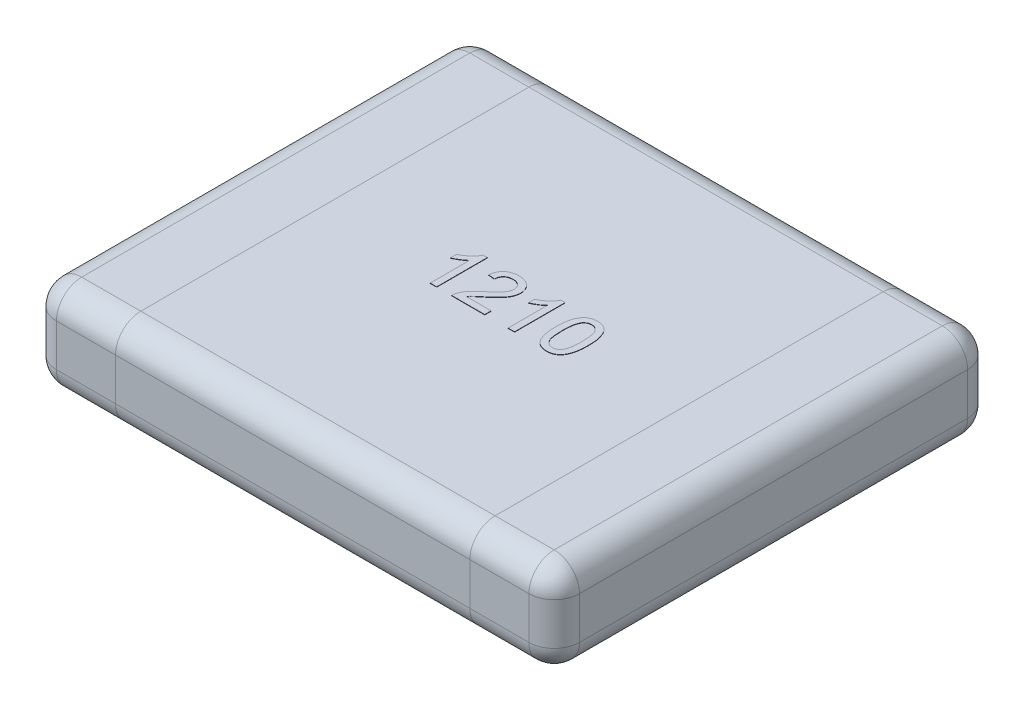
from build123d import *

# Parameters (mm, degrees)
SKETCH1_W      = 3.1
SKETCH1_H      = 2.6
EXTRUDE1_DEPTH = 0.55
FILLET1_R      = 0.15
EXTRUDE2_DEPTH = 0.002


with BuildPart() as part:
    # Sketch1 → Extrude1 (new body)
    with BuildSketch(Plane(origin=(0, 0, 0), x_dir=(1, 0, 0), z_dir=(0, 1, 0))):
        Rectangle(SKETCH1_W, SKETCH1_H)
    extrude(amount=EXTRUDE1_DEPTH)

    # Fillet1
    fillet1_edges = [part.edges().sort_by_distance(p)[0] for p in [
        (1.55, 0.55, 0),
        (0, 0.55, -1.3),
        (-1.55, 0.55, 0),
        (0, 0, -1.3),
        (1.55, 0, 0),
        (0, 0, 1.3),
        (-1.55, 0, 0),
        (0, 0.55, 1.3),
        (-1.55, 0.275, -1.3),
        (1.55, 0.275, -1.3),
        (1.55, 0.275, 1.3),
        (-1.55, 0.275, 1.3),
    ]]
    fillet(fillet1_edges, radius=FILLET1_R)

    # Sketch3 → Extrude2 (add)
    with BuildSketch(Plane(origin=(0, 0.55, 0), x_dir=(1, 0, 0), z_dir=(0, 1, 0))):
        with BuildLine():
            Line((-0.296153846, -0.15), (-0.334615385, -0.15))
            Line((-0.334615385, -0.15), (-0.334615385, 0.083774038))
            add(Edge.make_bspline(
                [(-0.334615385, 0.083774038), (-0.336830003, 0.081638311), (-0.341432846, 0.077199436), (-0.349213465, 0.070917319), (-0.35789763, 0.064550127), (-0.367372572, 0.05842736), (-0.377030672, 0.052663436), (-0.386363982, 0.047479672), (-0.39521668, 0.04309295), (-0.401047999, 0.040694273), (-0.403846154, 0.039543269)],
                knots=[0, 0, 0, 0, 9.226e-06, 1.9175e-05, 2.9969e-05, 4.1521e-05, 5.3002e-05, 6.3707e-05, 7.3544e-05, 8.2619e-05, 8.2619e-05, 8.2619e-05, 8.2619e-05], degree=3))
            Line((-0.403846154, 0.039543269), (-0.403846154, 0.075))
            add(Edge.make_bspline(
                [(-0.403846154, 0.075), (-0.399040034, 0.077475162), (-0.389567455, 0.082353558), (-0.37618475, 0.09077922), (-0.363690555, 0.099912985), (-0.352291699, 0.10975283), (-0.342073351, 0.119810917), (-0.333462201, 0.129959923), (-0.326256938, 0.139827828), (-0.322641922, 0.146709597), (-0.320913462, 0.15)],
                knots=[0, 0, 0, 0, 1.6212e-05, 3.1953e-05, 4.7386e-05, 6.26e-05, 7.7091e-05, 9.0349e-05, 0.000102505, 0.000113642, 0.000113642, 0.000113642, 0.000113642], degree=3))
            Line((-0.320913462, 0.15), (-0.296153846, 0.15))
            Line((-0.296153846, 0.15), (-0.296153846, -0.15))
        make_face()
        with BuildLine():
            Line((-0.011538462, -0.111538462), (-0.011538462, -0.15))
            Line((-0.011538462, -0.15), (-0.207692308, -0.15))
            add(Edge.make_bspline(
                [(-0.207692308, -0.15), (-0.207696323, -0.147714123), (-0.207704342, -0.14315003), (-0.206932024, -0.136400026), (-0.205722419, -0.129739566), (-0.204354719, -0.125468478), (-0.203665865, -0.123317308)],
                knots=[0, 0, 0, 0, 6.852e-06, 1.3681e-05, 2.0352e-05, 2.7121e-05, 2.7121e-05, 2.7121e-05, 2.7121e-05], degree=3))
            add(Edge.make_bspline(
                [(-0.203665865, -0.123317308), (-0.202393093, -0.119802551), (-0.199801518, -0.112645929), (-0.19455096, -0.102319922), (-0.188375063, -0.092056365), (-0.182361958, -0.08370038), (-0.176855252, -0.077024532), (-0.172237162, -0.071801454), (-0.167119471, -0.066455018), (-0.161506278, -0.060986201), (-0.155451607, -0.055359583), (-0.148947197, -0.049556401), (-0.141916239, -0.043684801), (-0.137007895, -0.039792861), (-0.134495192, -0.037800481)],
                knots=[0, 0, 0, 0, 1.1205e-05, 2.2816e-05, 3.4678e-05, 4.712e-05, 5.3653e-05, 6.0635e-05, 6.8031e-05, 7.5851e-05, 8.4142e-05, 9.2826e-05, 0.000101998, 0.000111618, 0.000111618, 0.000111618, 0.000111618], degree=3))
            add(Edge.make_bspline(
                [(-0.134495192, -0.037800481), (-0.130635061, -0.034551471), (-0.123202132, -0.028295295), (-0.112705672, -0.019011711), (-0.103118865, -0.010391377), (-0.094594368, -0.002283205), (-0.087062462, 0.005234162), (-0.080505461, 0.012143692), (-0.074866946, 0.018423822), (-0.070215752, 0.024301865), (-0.066291398, 0.029852373), (-0.062965854, 0.035266551), (-0.060194454, 0.040638972), (-0.057886249, 0.045952637), (-0.056060655, 0.05123027), (-0.054816253, 0.056487246), (-0.053972343, 0.061671403), (-0.053887909, 0.065120999), (-0.053846154, 0.066826923)],
                knots=[0, 0, 0, 0, 1.5136e-05, 2.9145e-05, 4.2036e-05, 5.3811e-05, 6.4435e-05, 7.3957e-05, 8.2386e-05, 8.9745e-05, 9.643e-05, 0.000102769, 0.00010879, 0.00011455, 0.000120137, 0.000125516, 0.000130743, 0.000135857, 0.000135857, 0.000135857, 0.000135857], degree=3))
            add(Edge.make_bspline(
                [(-0.053846154, 0.066826923), (-0.053887914, 0.068512943), (-0.053969845, 0.071820821), (-0.054747201, 0.076661881), (-0.055829343, 0.081323937), (-0.057578837, 0.085723063), (-0.059661262, 0.089989532), (-0.062332474, 0.093988532), (-0.065422517, 0.097819726), (-0.068960356, 0.101382104), (-0.072824504, 0.104724183), (-0.077142138, 0.107502263), (-0.081629679, 0.110003363), (-0.086441941, 0.11201439), (-0.091571106, 0.113491124), (-0.096979835, 0.114562852), (-0.10266727, 0.115242385), (-0.106548545, 0.115336486), (-0.108533654, 0.115384615)],
                knots=[0, 0, 0, 0, 5.054e-06, 9.915e-06, 1.4681e-05, 1.938e-05, 2.4083e-05, 2.89e-05, 3.3772e-05, 3.8829e-05, 4.3946e-05, 4.9063e-05, 5.4199e-05, 5.9345e-05, 6.4669e-05, 7.0185e-05, 7.5872e-05, 8.1827e-05, 8.1827e-05, 8.1827e-05, 8.1827e-05], degree=3))
            add(Edge.make_bspline(
                [(-0.108533654, 0.115384615), (-0.110618956, 0.115336725), (-0.114700045, 0.115242999), (-0.120665504, 0.114560756), (-0.126328674, 0.113518381), (-0.131676037, 0.111924678), (-0.136701084, 0.109917004), (-0.141383351, 0.107389877), (-0.145797819, 0.104537208), (-0.149805459, 0.101159863), (-0.153429516, 0.097415076), (-0.156646835, 0.093338135), (-0.159282944, 0.088850365), (-0.161459952, 0.084050442), (-0.163210448, 0.078923275), (-0.164481249, 0.07342967), (-0.165174098, 0.067585487), (-0.165313425, 0.063583392), (-0.165384615, 0.061538462)],
                knots=[0, 0, 0, 0, 6.255e-06, 1.2241e-05, 1.7992e-05, 2.3507e-05, 2.8953e-05, 3.4195e-05, 3.9446e-05, 4.4693e-05, 4.9878e-05, 5.506e-05, 6.0233e-05, 6.5451e-05, 7.0848e-05, 7.6461e-05, 8.2334e-05, 8.8471e-05, 8.8471e-05, 8.8471e-05, 8.8471e-05], degree=3))
            Line((-0.165384615, 0.061538462), (-0.203846154, 0.065384615))
            add(Edge.make_bspline(
                [(-0.203846154, 0.065384615), (-0.203452638, 0.068736632), (-0.202687086, 0.075257693), (-0.200780201, 0.084702351), (-0.198103106, 0.09348859), (-0.194899737, 0.101738909), (-0.190884012, 0.109312863), (-0.18634458, 0.11636711), (-0.18099053, 0.122677919), (-0.175075725, 0.128444216), (-0.168535362, 0.133525841), (-0.161430878, 0.137965346), (-0.153765522, 0.141678718), (-0.145581988, 0.144753235), (-0.136861488, 0.147085948), (-0.12761636, 0.148758724), (-0.117831734, 0.149789842), (-0.111120341, 0.149928948), (-0.107692308, 0.15)],
                knots=[0, 0, 0, 0, 1.0123e-05, 1.9693e-05, 2.8857e-05, 3.7651e-05, 4.6199e-05, 5.4533e-05, 6.2766e-05, 7.0968e-05, 7.9275e-05, 8.7563e-05, 9.6056e-05, 0.000104785, 0.00011375, 0.000123098, 0.000132946, 0.000143229, 0.000143229, 0.000143229, 0.000143229], degree=3))
            add(Edge.make_bspline(
                [(-0.107692308, 0.15), (-0.104223243, 0.149940596), (-0.097465484, 0.149824877), (-0.087618344, 0.14864084), (-0.078327294, 0.146796713), (-0.069558275, 0.144226564), (-0.061363096, 0.140856333), (-0.053735451, 0.136738671), (-0.046640172, 0.131913745), (-0.040195807, 0.126323636), (-0.034384754, 0.120221095), (-0.029292223, 0.113708369), (-0.025034622, 0.106813279), (-0.021409539, 0.09962981), (-0.018720681, 0.092006182), (-0.016829827, 0.084046037), (-0.015544936, 0.075742575), (-0.015438766, 0.070077103), (-0.015384615, 0.0671875)],
                knots=[0, 0, 0, 0, 1.0403e-05, 2.0265e-05, 2.9705e-05, 3.8794e-05, 4.7633e-05, 5.6238e-05, 6.4755e-05, 7.3321e-05, 8.178e-05, 9.0002e-05, 9.8073e-05, 0.000106055, 0.000114096, 0.000122258, 0.000130579, 0.00013924, 0.00013924, 0.00013924, 0.00013924], degree=3))
            add(Edge.make_bspline(
                [(-0.015384615, 0.0671875), (-0.015467303, 0.06421876), (-0.01563286, 0.058274728), (-0.016925056, 0.049390154), (-0.019136019, 0.040601997), (-0.022067165, 0.0318033), (-0.026071721, 0.022959142), (-0.031130797, 0.013947517), (-0.037407134, 0.004735138), (-0.04344321, -0.003096409), (-0.049061817, -0.009661219), (-0.054042181, -0.015064442), (-0.059804175, -0.020805005), (-0.066131643, -0.027081717), (-0.073282651, -0.033671804), (-0.081051734, -0.040772611), (-0.089608959, -0.048197271), (-0.095549342, -0.053269443), (-0.098617788, -0.055889423)],
                knots=[0, 0, 0, 0, 8.904e-06, 1.7828e-05, 2.6865e-05, 3.6063e-05, 4.5612e-05, 5.5944e-05, 6.7028e-05, 7.9024e-05, 8.5588e-05, 9.2946e-05, 0.000101063, 0.000109987, 0.000119681, 0.000130232, 0.000141562, 0.000153666, 0.000153666, 0.000153666, 0.000153666], degree=3))
            add(Edge.make_bspline(
                [(-0.098617788, -0.055889423), (-0.101245449, -0.058028619), (-0.106255994, -0.062107737), (-0.113384465, -0.068021343), (-0.119769407, -0.07344396), (-0.12556013, -0.078198712), (-0.130545741, -0.08251558), (-0.13490185, -0.086205504), (-0.138470198, -0.089454013), (-0.14390416, -0.094388563), (-0.150786737, -0.101422266), (-0.155858114, -0.108256719), (-0.158293269, -0.111538462)],
                knots=[0, 0, 0, 0, 1.0165e-05, 1.9383e-05, 2.7786e-05, 3.5295e-05, 4.1859e-05, 4.7569e-05, 5.242e-05, 5.6334e-05, 6.9594e-05, 8.1844e-05, 8.1844e-05, 8.1844e-05, 8.1844e-05], degree=3))
            Line((-0.158293269, -0.111538462), (-0.011538462, -0.111538462))
        make_face()
        with BuildLine():
            Line((0.165384615, -0.15), (0.126923077, -0.15))
            Line((0.126923077, -0.15), (0.126923077, 0.083774038))
            add(Edge.make_bspline(
                [(0.126923077, 0.083774038), (0.124708458, 0.081638311), (0.120105616, 0.077199436), (0.112324997, 0.070917319), (0.103640832, 0.064550127), (0.09416589, 0.05842736), (0.08450779, 0.052663436), (0.075174479, 0.047479672), (0.066321782, 0.04309295), (0.060490463, 0.040694273), (0.057692308, 0.039543269)],
                knots=[0, 0, 0, 0, 9.226e-06, 1.9175e-05, 2.9969e-05, 4.1521e-05, 5.3002e-05, 6.3707e-05, 7.3544e-05, 8.2619e-05, 8.2619e-05, 8.2619e-05, 8.2619e-05], degree=3))
            Line((0.057692308, 0.039543269), (0.057692308, 0.075))
            add(Edge.make_bspline(
                [(0.057692308, 0.075), (0.062498428, 0.077475162), (0.071971006, 0.082353558), (0.085353711, 0.09077922), (0.097847906, 0.099912985), (0.109246762, 0.10975283), (0.11946511, 0.119810917), (0.128076261, 0.129959923), (0.135281523, 0.139827828), (0.13889654, 0.146709597), (0.140625, 0.15)],
                knots=[0, 0, 0, 0, 1.6212e-05, 3.1953e-05, 4.7386e-05, 6.26e-05, 7.7091e-05, 9.0349e-05, 0.000102505, 0.000113642, 0.000113642, 0.000113642, 0.000113642], degree=3))
            Line((0.140625, 0.15), (0.165384615, 0.15))
            Line((0.165384615, 0.15), (0.165384615, -0.15))
        make_face()
        with BuildLine():
            add(Edge.make_bspline(
                [(0.261538462, -0.002043269), (0.261577212, 0.002244006), (0.261653106, 0.010640973), (0.262123858, 0.022927244), (0.262945753, 0.034595007), (0.264172615, 0.045634129), (0.265625449, 0.056069528), (0.267514143, 0.06588631), (0.269639198, 0.075106502), (0.272188883, 0.083720493), (0.274990152, 0.091802347), (0.278168281, 0.0993391), (0.281744108, 0.106322761), (0.285541902, 0.112825754), (0.289761587, 0.118746931), (0.294148472, 0.124252464), (0.299021369, 0.129140445), (0.304177653, 0.13353664), (0.309693251, 0.137416027), (0.31553898, 0.140763469), (0.321692348, 0.143719019), (0.32827063, 0.145943957), (0.335137264, 0.147757753), (0.342345104, 0.149092003), (0.349902094, 0.149878588), (0.355066234, 0.149959072), (0.357692308, 0.15)],
                knots=[0, 0, 0, 0, 1.2862e-05, 2.5191e-05, 3.688e-05, 4.7943e-05, 5.8507e-05, 6.8478e-05, 7.7924e-05, 8.6881e-05, 9.5415e-05, 0.000103574, 0.000111395, 0.00011894, 0.000126142, 0.000133191, 0.000140033, 0.000146812, 0.000153498, 0.000160229, 0.000167003, 0.000173941, 0.000181025, 0.000188297, 0.00019591, 0.000203786, 0.000203786, 0.000203786, 0.000203786], degree=3))
            add(Edge.make_bspline(
                [(0.357692308, 0.15), (0.361545099, 0.149886731), (0.369114062, 0.149664209), (0.380164787, 0.147849358), (0.390579383, 0.144744777), (0.400351085, 0.140556563), (0.409312845, 0.135236725), (0.417316074, 0.128769652), (0.424274445, 0.121223246), (0.430112018, 0.112508085), (0.435214639, 0.102864591), (0.439747696, 0.092249481), (0.443845448, 0.080674651), (0.446753302, 0.070313561), (0.448827472, 0.061369501), (0.450200407, 0.053992694), (0.451340219, 0.046033077), (0.452213469, 0.037509907), (0.45292995, 0.028432744), (0.453483255, 0.018795935), (0.453764114, 0.008575397), (0.453818295, 0.001562641), (0.453846154, -0.002043269)],
                knots=[0, 0, 0, 0, 1.1554e-05, 2.2698e-05, 3.348e-05, 4.4085e-05, 5.4516e-05, 6.4643e-05, 7.485e-05, 8.5185e-05, 9.602e-05, 0.000107541, 0.000119781, 0.000132832, 0.000139801, 0.000147321, 0.000155335, 0.000163916, 0.000173019, 0.00018265, 0.000192871, 0.000203689, 0.000203689, 0.000203689, 0.000203689], degree=3))
            add(Edge.make_bspline(
                [(0.453846154, -0.002043269), (0.453806678, -0.006310407), (0.453729554, -0.0146471), (0.453271416, -0.026834856), (0.452399997, -0.038414591), (0.4513277, -0.049412832), (0.449705539, -0.059800218), (0.447957572, -0.069620882), (0.445795769, -0.07883023), (0.443273453, -0.087432298), (0.440432752, -0.095472571), (0.437317483, -0.103011813), (0.433867025, -0.110044871), (0.429978677, -0.11650315), (0.425830349, -0.122472371), (0.42139166, -0.127974928), (0.416568504, -0.132931621), (0.411365754, -0.137314631), (0.405888882, -0.141262812), (0.400028941, -0.144643304), (0.393811578, -0.147443983), (0.387278334, -0.149838424), (0.38036292, -0.15159293), (0.37311987, -0.152935977), (0.365522497, -0.153726861), (0.360338382, -0.153805841), (0.357692308, -0.153846154)],
                knots=[0, 0, 0, 0, 1.2802e-05, 2.5011e-05, 3.658e-05, 4.7637e-05, 5.815e-05, 6.811e-05, 7.7556e-05, 8.6513e-05, 9.499e-05, 0.000103126, 0.000110974, 0.000118467, 0.000125719, 0.000132767, 0.000139652, 0.000146431, 0.000153152, 0.000159883, 0.000166686, 0.000173587, 0.000180729, 0.000188061, 0.000195673, 0.00020361, 0.00020361, 0.00020361, 0.00020361], degree=3))
            add(Edge.make_bspline(
                [(0.357692308, -0.153846154), (0.354222998, -0.153747192), (0.347458799, -0.153554242), (0.337580184, -0.152243272), (0.328308578, -0.149935902), (0.319565779, -0.146841394), (0.311450058, -0.142702311), (0.303922667, -0.137666308), (0.296832347, -0.131850554), (0.292750728, -0.127262057), (0.290685096, -0.124939904)],
                knots=[0, 0, 0, 0, 1.0408e-05, 2.0292e-05, 2.9825e-05, 3.9025e-05, 4.8056e-05, 5.7073e-05, 6.616e-05, 7.5471e-05, 7.5471e-05, 7.5471e-05, 7.5471e-05], degree=3))
            add(Edge.make_bspline(
                [(0.290685096, -0.124939904), (0.288307506, -0.121510195), (0.283404814, -0.11443799), (0.277666637, -0.102379223), (0.272548083, -0.089104214), (0.268530955, -0.074352508), (0.265384543, -0.058241513), (0.263112049, -0.040739616), (0.26182604, -0.021854376), (0.261636485, -0.008796046), (0.261538462, -0.002043269)],
                knots=[0, 0, 0, 0, 1.2501e-05, 2.5778e-05, 3.993e-05, 5.5152e-05, 7.157e-05, 8.9147e-05, 0.000108063, 0.000128321, 0.000128321, 0.000128321, 0.000128321], degree=3))
        make_face()
        with BuildLine():
            add(Edge.make_bspline(
                [(0.3, -0.001923077), (0.300038189, -0.007693168), (0.300111292, -0.018738399), (0.300875037, -0.034518417), (0.302189794, -0.048754147), (0.303927988, -0.061425879), (0.306223107, -0.072550754), (0.309104901, -0.082100422), (0.312353369, -0.090189501), (0.316373285, -0.096717734), (0.32077465, -0.102039196), (0.325318759, -0.106615825), (0.330112518, -0.110505855), (0.335124649, -0.113749347), (0.340432919, -0.116205105), (0.345979283, -0.117985045), (0.351764947, -0.119009373), (0.355705248, -0.119156549), (0.357692308, -0.119230769)],
                knots=[0, 0, 0, 0, 1.7309e-05, 3.3134e-05, 4.7378e-05, 6.0186e-05, 7.1489e-05, 8.1413e-05, 9.0085e-05, 9.7558e-05, 0.000104306, 0.000110765, 0.000116876, 0.000122794, 0.000128628, 0.000134368, 0.000140227, 0.000146187, 0.000146187, 0.000146187, 0.000146187], degree=3))
            add(Edge.make_bspline(
                [(0.357692308, -0.119230769), (0.35967887, -0.119154928), (0.363618184, -0.119004535), (0.369417217, -0.118002795), (0.374942001, -0.116131225), (0.380242356, -0.11368414), (0.385290917, -0.110514577), (0.390061133, -0.106609854), (0.394629179, -0.102035942), (0.399010773, -0.096652628), (0.403000063, -0.090094213), (0.406309468, -0.082011723), (0.409146351, -0.072445331), (0.411454064, -0.061326124), (0.413199428, -0.048674427), (0.414506235, -0.03447818), (0.415275092, -0.018718466), (0.415346988, -0.007693194), (0.415384615, -0.001923077)],
                knots=[0, 0, 0, 0, 5.96e-06, 1.1819e-05, 1.7578e-05, 2.3412e-05, 2.9298e-05, 3.5408e-05, 4.1867e-05, 4.8662e-05, 5.6186e-05, 6.4803e-05, 7.4784e-05, 8.6088e-05, 9.8836e-05, 0.00011308, 0.000128845, 0.000146154, 0.000146154, 0.000146154, 0.000146154], degree=3))
            add(Edge.make_bspline(
                [(0.415384615, -0.001923077), (0.415348193, 0.003726983), (0.415278409, 0.014552283), (0.414489723, 0.030028299), (0.41325378, 0.044025088), (0.411563207, 0.056555555), (0.409316435, 0.067606095), (0.406591408, 0.077200235), (0.403344131, 0.085317512), (0.39948313, 0.092039466), (0.395185063, 0.097553292), (0.390695324, 0.102325988), (0.385901671, 0.10638501), (0.380719172, 0.109641218), (0.375314872, 0.112268205), (0.369564591, 0.114076165), (0.363524851, 0.115186918), (0.359379855, 0.115317963), (0.357271635, 0.115384615)],
                knots=[0, 0, 0, 0, 1.6949e-05, 3.2473e-05, 4.6473e-05, 5.9094e-05, 7.0385e-05, 8.0274e-05, 8.8979e-05, 9.6545e-05, 0.000103444, 0.000109906, 0.000116177, 0.000122229, 0.000128223, 0.000134153, 0.000140259, 0.000146579, 0.000146579, 0.000146579, 0.000146579], degree=3))
            add(Edge.make_bspline(
                [(0.357271635, 0.115384615), (0.355284699, 0.115332466), (0.351366718, 0.115229635), (0.34563028, 0.114248109), (0.340193925, 0.112606778), (0.33499537, 0.110383437), (0.330164394, 0.107391258), (0.325509413, 0.103897677), (0.321248448, 0.099641138), (0.318680828, 0.096459016), (0.317367788, 0.094831731)],
                knots=[0, 0, 0, 0, 5.957e-06, 1.1747e-05, 1.7393e-05, 2.2965e-05, 2.8654e-05, 3.4399e-05, 4.0391e-05, 4.6662e-05, 4.6662e-05, 4.6662e-05, 4.6662e-05], degree=3))
            add(Edge.make_bspline(
                [(0.317367788, 0.094831731), (0.315938289, 0.092441753), (0.312919488, 0.087394622), (0.309541626, 0.078622501), (0.306557755, 0.068597636), (0.30410104, 0.057165788), (0.30232378, 0.044346567), (0.300920701, 0.03015486), (0.300191854, 0.014570853), (0.300065716, 0.003726591), (0.3, -0.001923077)],
                knots=[0, 0, 0, 0, 8.341e-06, 1.7615e-05, 2.8091e-05, 3.9714e-05, 5.2649e-05, 6.6899e-05, 8.2483e-05, 9.9433e-05, 9.9433e-05, 9.9433e-05, 9.9433e-05], degree=3))
        make_face(mode=Mode.SUBTRACT)
    extrude(amount=EXTRUDE2_DEPTH)


solid = part.part
